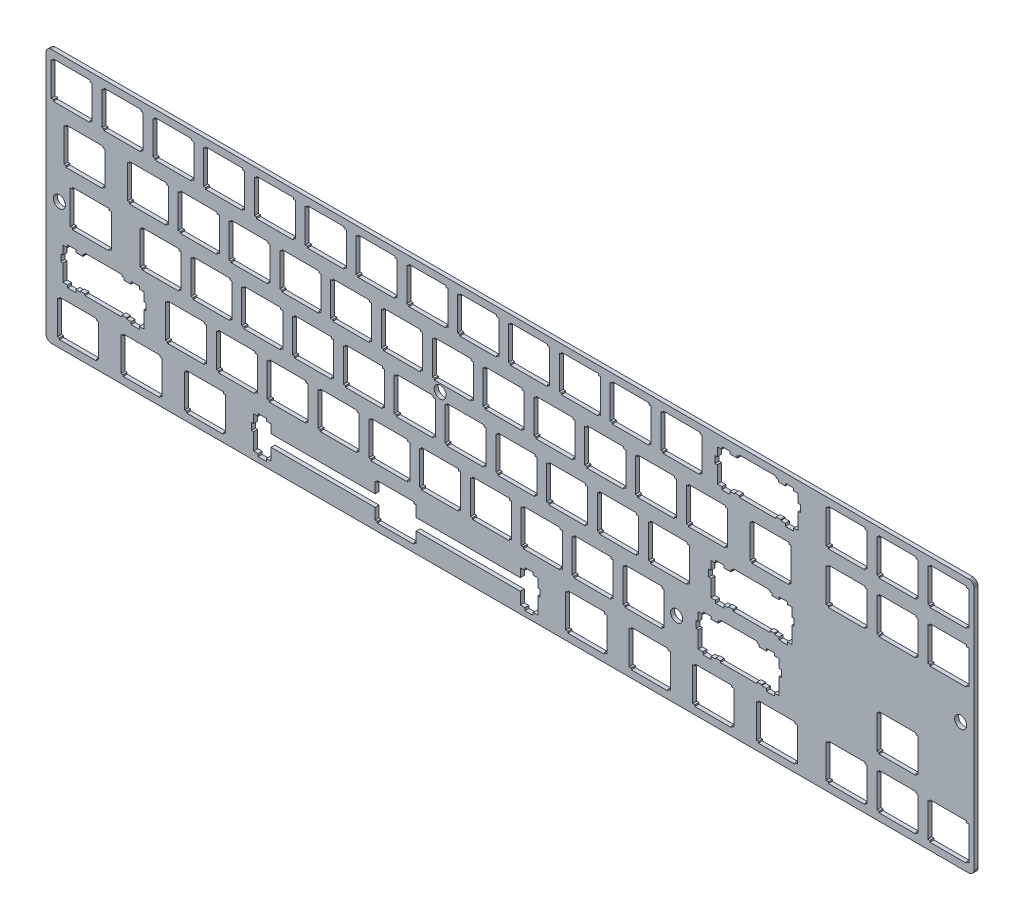
from build123d import *

# Parameters (mm, degrees)
MODEL_R             = 2.25
BOSS_EXTRUDE1_DEPTH = 1.5


with BuildPart() as part:
    # Model → Boss-Extrude1 (new body)
    with BuildSketch(Plane.XY):
        Polygon((346.115, 95.8536), (345.958, 95.8603), (2.096, 95.8603), (1.9389, 95.8536), (1.7818, 95.8356), (1.62884, 95.8053), (1.47588, 95.7626), (1.32981, 95.7076), (1.18787, 95.6426), (1.05006, 95.5657), (0.919152, 95.4786), (0.796505, 95.3809), (0.680752, 95.2747), (0.574643, 95.159), (0.4768, 95.0366), (0.389985, 94.9053), (0.312815, 94.7678), (0.248047, 94.6256), (0.192925, 94.4795), (0.150206, 94.3268), (0.119889, 94.1737), (0.101975, 94.0167), (0.0950846, 93.8597), (0.0950846, 49.660655), (0.0950846, 45.160655), (0.0950846, 2.40881), (0.101975, 2.25309), (0.119889, 2.09737), (0.150206, 1.94303), (0.192925, 1.79145), (0.248047, 1.644), (0.312815, 1.50206), (0.389985, 1.36563), (0.4768, 1.23472), (0.574643, 1.1107), (0.680752, 0.994943), (0.796505, 0.888834), (0.919152, 0.790995), (1.05006, 0.704176), (1.18787, 0.627006), (1.32981, 0.56224), (1.47588, 0.507118), (1.62884, 0.4644), (1.7818, 0.434082), (1.9389, 0.416168), (2.096, 0.410655), (345.958, 0.410655), (346.115, 0.416168), (346.272, 0.434082), (346.425, 0.4644), (346.577, 0.507118), (346.724, 0.56224), (346.866, 0.627006), (347.004, 0.704176), (347.135, 0.790995), (347.258, 0.888834), (347.373, 0.994943), (347.479, 1.1107), (347.577, 1.23472), (347.664, 1.36563), (347.741, 1.50206), (347.806, 1.644), (347.861, 1.79145), (347.904, 1.94303), (347.934, 2.09737), (347.952, 2.25309), (347.959, 2.41019), (347.959, 45.160655), (347.959, 49.660655), (347.959, 93.8597), (347.952, 94.0167), (347.934, 94.1737), (347.904, 94.3268), (347.861, 94.4795), (347.806, 94.6256), (347.741, 94.7678), (347.664, 94.9053), (347.577, 95.0366), (347.479, 95.159), (347.373, 95.2747), (347.258, 95.3809), (347.135, 95.4786), (347.004, 95.5657), (346.866, 95.6426), (346.724, 95.7076), (346.577, 95.7626), (346.425, 95.8053), (346.272, 95.8356), align=None)
        Polygon((5.2021, 16.3366), (5.2021, 16.9361), (19.0018, 16.9361), (19.0018, 16.3366), (19.801, 16.3366), (19.801, 3.73585), (19.0018, 3.73585), (19.0018, 3.13504), (5.2021, 3.13504), (5.2021, 3.73585), (4.40147, 3.73585), (4.40147, 16.3366), align=None, mode=Mode.SUBTRACT)
        Polygon((29.0132, 16.3366), (29.0132, 16.9361), (42.8128, 16.9361), (42.8128, 16.3366), (43.6136, 16.3366), (43.6136, 3.73585), (42.8128, 3.73585), (42.8128, 3.13504), (29.0132, 3.13504), (29.0132, 3.73585), (28.214, 3.73585), (28.214, 16.3366), align=None, mode=Mode.SUBTRACT)
        Polygon((52.8271, 16.3366), (52.8271, 16.9361), (66.6267, 16.9361), (66.6267, 16.3366), (67.4261, 16.3366), (67.4261, 3.73585), (66.6267, 3.73585), (66.6267, 3.13504), (52.8271, 3.13504), (52.8271, 3.73585), (52.0266, 3.73585), (52.0266, 16.3366), align=None, mode=Mode.SUBTRACT)
        Polygon((124.263, 16.3366), (124.263, 16.9361), (138.063, 16.9361), (138.063, 16.3366), (138.864, 16.3366), (138.864, 12.2356), (177.888, 12.2356), (177.888, 15.4657), (179.614, 15.4657), (179.614, 16.3849), (182.714, 16.3849), (182.714, 15.4657), (184.438, 15.4657), (184.438, 12.2356), (185.263, 12.2356), (185.263, 9.63524), (184.438, 9.63524), (184.438, 3.36655), (182.714, 3.36655), (182.714, 2.38538), (179.614, 2.38538), (179.614, 3.36655), (177.888, 3.36655), (177.888, 7.83551), (138.864, 7.83551), (138.864, 3.73585), (138.063, 3.73585), (138.063, 3.13504), (124.263, 3.13504), (124.263, 3.73585), (123.464, 3.73585), (123.464, 7.83551), (84.4381, 7.83551), (84.4381, 3.36655), (82.714, 3.36655), (82.714, 2.38538), (79.6135, 2.38538), (79.6135, 3.36655), (77.888, 3.36655), (77.888, 9.63524), (77.064, 9.63524), (77.064, 12.2356), (77.888, 12.2356), (77.888, 15.4657), (79.6135, 15.4657), (79.6135, 16.3849), (82.714, 16.3849), (82.714, 15.4657), (84.4381, 15.4657), (84.4381, 12.2356), (123.464, 12.2356), (123.464, 16.3366), align=None, mode=Mode.SUBTRACT)
        Polygon((29.326, 35.3868), (29.326, 34.5157), (30.2521, 34.5157), (31.976, 34.5157), (31.976, 35.4348), (35.0766, 35.4348), (35.0766, 34.5157), (36.8018, 34.5157), (36.8018, 31.2856), (37.6259, 31.2856), (37.6259, 28.6852), (36.8018, 28.6852), (36.8018, 22.4152), (35.0766, 22.4152), (35.0766, 21.4354), (31.976, 21.4354), (31.976, 22.4152), (30.2521, 22.4152), (30.2521, 22.7858), (29.326, 22.7858), (28.5268, 22.7858), (28.5268, 22.185), (14.7271, 22.185), (14.7271, 22.7858), (13.9265, 22.7858), (13.0018, 22.7858), (13.0018, 22.4152), (11.2765, 22.4152), (11.2765, 21.4354), (8.17591, 21.4354), (8.17591, 22.4152), (6.45199, 22.4152), (6.45199, 28.6852), (5.62652, 28.6852), (5.62652, 31.2856), (6.45199, 31.2856), (6.45199, 34.5157), (8.17591, 34.5157), (8.17591, 35.4348), (11.2765, 35.4348), (11.2765, 34.5157), (13.0018, 34.5157), (13.9265, 34.5157), (13.9265, 35.3868), (14.7271, 35.3868), (14.7271, 35.9876), (28.5268, 35.9876), (28.5268, 35.3868), align=None, mode=Mode.SUBTRACT)
        Polygon((45.6819, 35.3868), (45.6819, 35.9876), (59.4829, 35.9876), (59.4829, 35.3868), (60.2823, 35.3868), (60.2823, 22.7858), (59.4829, 22.7858), (59.4829, 22.185), (45.6819, 22.185), (45.6819, 22.7858), (44.8829, 22.7858), (44.8829, 35.3868), align=None, mode=Mode.SUBTRACT)
        Polygon((64.7319, 35.3868), (64.7319, 35.9876), (78.5329, 35.9876), (78.5329, 35.3868), (79.3323, 35.3868), (79.3323, 22.7858), (78.5329, 22.7858), (78.5329, 22.185), (64.7319, 22.185), (64.7319, 22.7858), (63.9329, 22.7858), (63.9329, 35.3868), align=None, mode=Mode.SUBTRACT)
        with BuildLine():
            ThreePointArc((5.0950846, 50.151223349), (7.3450846, 47.901223349), (5.0950846, 45.651223349))
            ThreePointArc((5.0950846, 45.651223349), (2.8450846, 47.901223349), (5.0950846, 50.151223349))
        make_face(mode=Mode.SUBTRACT)
        Polygon((83.7819, 35.3868), (83.7819, 35.9876), (97.5829, 35.9876), (97.5829, 35.3868), (98.3823, 35.3868), (98.3823, 22.7858), (97.5829, 22.7858), (97.5829, 22.185), (83.7819, 22.185), (83.7819, 22.7858), (82.9829, 22.7858), (82.9829, 35.3868), align=None, mode=Mode.SUBTRACT)
        Polygon((102.832, 35.3868), (102.832, 35.9876), (116.633, 35.9876), (116.633, 35.3868), (117.432, 35.3868), (117.432, 22.7858), (116.633, 22.7858), (116.633, 22.185), (102.832, 22.185), (102.832, 22.7858), (102.033, 22.7858), (102.033, 35.3868), align=None, mode=Mode.SUBTRACT)
        Polygon((121.882, 35.3868), (121.882, 35.9876), (135.683, 35.9876), (135.683, 35.3868), (136.482, 35.3868), (136.482, 22.7858), (135.683, 22.7858), (135.683, 22.185), (121.882, 22.185), (121.882, 22.7858), (121.083, 22.7858), (121.083, 35.3868), align=None, mode=Mode.SUBTRACT)
        Polygon((140.932, 35.3868), (140.932, 35.9876), (154.733, 35.9876), (154.733, 35.3868), (155.532, 35.3868), (155.532, 22.7858), (154.733, 22.7858), (154.733, 22.185), (140.932, 22.185), (140.932, 22.7858), (140.133, 22.7858), (140.133, 35.3868), align=None, mode=Mode.SUBTRACT)
        Polygon((159.982, 35.3868), (159.982, 35.9876), (173.783, 35.9876), (173.783, 35.3868), (174.582, 35.3868), (174.582, 22.7858), (173.783, 22.7858), (173.783, 22.185), (159.982, 22.185), (159.982, 22.7858), (159.183, 22.7858), (159.183, 35.3868), align=None, mode=Mode.SUBTRACT)
        Polygon((195.702, 16.3366), (195.702, 16.9361), (209.502, 16.9361), (209.502, 16.3366), (210.301, 16.3366), (210.301, 3.73585), (209.502, 3.73585), (209.502, 3.13504), (195.702, 3.13504), (195.702, 3.73585), (194.902, 3.73585), (194.902, 16.3366), align=None, mode=Mode.SUBTRACT)
        Polygon((219.513, 16.3366), (219.513, 16.9361), (233.313, 16.9361), (233.313, 16.3366), (234.114, 16.3366), (234.114, 3.73585), (233.313, 3.73585), (233.313, 3.13504), (219.513, 3.13504), (219.513, 3.73585), (218.714, 3.73585), (218.714, 16.3366), align=None, mode=Mode.SUBTRACT)
        Polygon((243.327, 16.3366), (243.327, 16.9361), (257.127, 16.9361), (257.127, 16.3366), (257.926, 16.3366), (257.926, 3.73585), (257.127, 3.73585), (257.127, 3.13504), (243.327, 3.13504), (243.327, 3.73585), (242.527, 3.73585), (242.527, 16.3366), align=None, mode=Mode.SUBTRACT)
        Polygon((267.138, 16.3366), (267.138, 16.9361), (280.938, 16.9361), (280.938, 16.3366), (281.739, 16.3366), (281.739, 3.73585), (280.938, 3.73585), (280.938, 3.13504), (267.138, 3.13504), (267.138, 3.73585), (266.339, 3.73585), (266.339, 16.3366), align=None, mode=Mode.SUBTRACT)
        Polygon((293.332, 16.3366), (293.332, 16.9361), (307.133, 16.9361), (307.133, 16.3366), (307.932, 16.3366), (307.932, 3.73585), (307.133, 3.73585), (307.133, 3.13504), (293.332, 3.13504), (293.332, 3.73585), (292.533, 3.73585), (292.533, 16.3366), align=None, mode=Mode.SUBTRACT)
        Polygon((312.382, 16.3366), (312.382, 16.9361), (326.183, 16.9361), (326.183, 16.3366), (326.982, 16.3366), (326.982, 3.73585), (326.183, 3.73585), (326.183, 3.13504), (312.382, 3.13504), (312.382, 3.73585), (311.583, 3.73585), (311.583, 16.3366), align=None, mode=Mode.SUBTRACT)
        Polygon((331.432, 16.3366), (331.432, 16.9361), (345.233, 16.9361), (345.233, 16.3366), (346.032, 16.3366), (346.032, 3.73585), (345.233, 3.73585), (345.233, 3.13504), (331.432, 3.13504), (331.432, 3.73585), (330.633, 3.73585), (330.633, 16.3366), align=None, mode=Mode.SUBTRACT)
        Polygon((179.032, 35.3868), (179.032, 35.9876), (192.833, 35.9876), (192.833, 35.3868), (193.632, 35.3868), (193.632, 22.7858), (192.833, 22.7858), (192.833, 22.185), (179.032, 22.185), (179.032, 22.7858), (178.233, 22.7858), (178.233, 35.3868), align=None, mode=Mode.SUBTRACT)
        Polygon((198.082, 35.3868), (198.082, 35.9876), (211.883, 35.9876), (211.883, 35.3868), (212.682, 35.3868), (212.682, 22.7858), (211.883, 22.7858), (211.883, 22.185), (198.082, 22.185), (198.082, 22.7858), (197.283, 22.7858), (197.283, 35.3868), align=None, mode=Mode.SUBTRACT)
        Polygon((217.132, 35.3868), (217.132, 35.9876), (230.933, 35.9876), (230.933, 35.3868), (231.732, 35.3868), (231.732, 22.7858), (230.933, 22.7858), (230.933, 22.185), (217.132, 22.185), (217.132, 22.7858), (216.333, 22.7858), (216.333, 35.3868), align=None, mode=Mode.SUBTRACT)
        with Locations((236.496, 29.175768349)):
            Circle(MODEL_R, mode=Mode.SUBTRACT)
        Polygon((252.851, 35.3868), (252.851, 35.9876), (266.652, 35.9876), (266.652, 35.3868), (267.451, 35.3868), (267.451, 34.5157), (268.377, 34.5157), (270.101, 34.5157), (270.101, 35.4348), (273.202, 35.4348), (273.202, 34.5157), (274.927, 34.5157), (274.927, 31.2856), (275.751, 31.2856), (275.751, 28.6852), (274.927, 28.6852), (274.927, 22.4152), (273.202, 22.4152), (273.202, 21.4354), (270.101, 21.4354), (270.101, 22.4152), (268.377, 22.4152), (268.377, 22.7858), (267.451, 22.7858), (266.652, 22.7858), (266.652, 22.185), (252.851, 22.185), (252.851, 22.7858), (252.052, 22.7858), (251.127, 22.7858), (251.127, 22.4152), (249.402, 22.4152), (249.402, 21.4354), (246.301, 21.4354), (246.301, 22.4152), (244.577, 22.4152), (244.577, 28.6852), (243.751, 28.6852), (243.751, 31.2856), (244.577, 31.2856), (244.577, 34.5157), (246.301, 34.5157), (246.301, 35.4348), (249.402, 35.4348), (249.402, 34.5157), (251.127, 34.5157), (252.052, 34.5157), (252.052, 35.3868), align=None, mode=Mode.SUBTRACT)
        Polygon((312.382, 35.3868), (312.382, 35.9876), (326.183, 35.9876), (326.183, 35.3868), (326.982, 35.3868), (326.982, 22.7858), (326.183, 22.7858), (326.183, 22.185), (312.382, 22.185), (312.382, 22.7858), (311.583, 22.7858), (311.583, 35.3868), align=None, mode=Mode.SUBTRACT)
        Polygon((272.214, 54.4354), (272.214, 53.5658), (273.138, 53.5658), (274.864, 53.5658), (274.864, 54.4862), (277.964, 54.4862), (277.964, 53.5658), (279.688, 53.5658), (279.688, 50.3357), (280.513, 50.3357), (280.513, 47.7365), (279.688, 47.7365), (279.688, 41.4666), (277.964, 41.4666), (277.964, 40.4855), (274.864, 40.4855), (274.864, 41.4666), (273.138, 41.4666), (273.138, 41.8359), (272.214, 41.8359), (271.413, 41.8359), (271.413, 41.2365), (257.613, 41.2365), (257.613, 41.8359), (256.814, 41.8359), (255.888, 41.8359), (255.888, 41.4666), (254.163, 41.4666), (254.163, 40.4855), (251.063, 40.4855), (251.063, 41.4666), (249.338, 41.4666), (249.338, 47.7365), (248.514, 47.7365), (248.514, 50.3357), (249.338, 50.3357), (249.338, 53.5658), (251.063, 53.5658), (251.063, 54.4862), (254.163, 54.4862), (254.163, 53.5658), (255.888, 53.5658), (256.814, 53.5658), (256.814, 54.4354), (257.613, 54.4354), (257.613, 55.0362), (271.413, 55.0362), (271.413, 54.4354), align=None, mode=Mode.SUBTRACT)
        with BuildLine():
            ThreePointArc((342.959, 45.651223349), (340.709, 47.901223349), (342.959, 50.151223349))
            ThreePointArc((342.959, 50.151223349), (345.209, 47.901223349), (342.959, 45.651223349))
        make_face(mode=Mode.SUBTRACT)
        Polygon((9.96322, 54.4354), (9.96322, 55.0362), (23.7629, 55.0362), (23.7629, 54.4354), (24.5635, 54.4354), (24.5635, 41.8359), (23.7629, 41.8359), (23.7629, 41.2365), (9.96322, 41.2365), (9.96322, 41.8359), (9.16397, 41.8359), (9.16397, 54.4354), align=None, mode=Mode.SUBTRACT)
        Polygon((36.1569, 54.4354), (36.1569, 55.0362), (49.9579, 55.0362), (49.9579, 54.4354), (50.7573, 54.4354), (50.7573, 41.8359), (49.9579, 41.8359), (49.9579, 41.2365), (36.1569, 41.2365), (36.1569, 41.8359), (35.3579, 41.8359), (35.3579, 54.4354), align=None, mode=Mode.SUBTRACT)
        Polygon((55.2069, 54.4354), (55.2069, 55.0362), (69.0079, 55.0362), (69.0079, 54.4354), (69.8073, 54.4354), (69.8073, 41.8359), (69.0079, 41.8359), (69.0079, 41.2365), (55.2069, 41.2365), (55.2069, 41.8359), (54.4079, 41.8359), (54.4079, 54.4354), align=None, mode=Mode.SUBTRACT)
        Polygon((74.2569, 54.4354), (74.2569, 55.0362), (88.0579, 55.0362), (88.0579, 54.4354), (88.8573, 54.4354), (88.8573, 41.8359), (88.0579, 41.8359), (88.0579, 41.2365), (74.2569, 41.2365), (74.2569, 41.8359), (73.4579, 41.8359), (73.4579, 54.4354), align=None, mode=Mode.SUBTRACT)
        Polygon((7.58197, 73.4868), (7.58197, 74.0847), (21.383, 74.0847), (21.383, 73.4868), (22.1823, 73.4868), (22.1823, 60.8859), (21.383, 60.8859), (21.383, 60.2865), (7.58197, 60.2865), (7.58197, 60.8859), (6.78272, 60.8859), (6.78272, 73.4868), align=None, mode=Mode.SUBTRACT)
        Polygon((31.3958, 73.4868), (31.3958, 74.0847), (45.1954, 74.0847), (45.1954, 73.4868), (45.9962, 73.4868), (45.9962, 60.8859), (45.1954, 60.8859), (45.1954, 60.2865), (31.3958, 60.2865), (31.3958, 60.8859), (30.5952, 60.8859), (30.5952, 73.4868), align=None, mode=Mode.SUBTRACT)
        Polygon((50.4458, 73.4868), (50.4458, 74.0847), (64.2454, 74.0847), (64.2454, 73.4868), (65.0462, 73.4868), (65.0462, 60.8859), (64.2454, 60.8859), (64.2454, 60.2865), (50.4458, 60.2865), (50.4458, 60.8859), (49.6454, 60.8859), (49.6454, 73.4868), align=None, mode=Mode.SUBTRACT)
        Polygon((69.4944, 73.4868), (69.4944, 74.0847), (83.2954, 74.0847), (83.2954, 73.4868), (84.0962, 73.4868), (84.0962, 60.8859), (83.2954, 60.8859), (83.2954, 60.2865), (69.4944, 60.2865), (69.4944, 60.8859), (68.6954, 60.8859), (68.6954, 73.4868), align=None, mode=Mode.SUBTRACT)
        Polygon((93.3069, 54.4354), (93.3069, 55.0362), (107.108, 55.0362), (107.108, 54.4354), (107.907, 54.4354), (107.907, 41.8359), (107.108, 41.8359), (107.108, 41.2365), (93.3069, 41.2365), (93.3069, 41.8359), (92.5079, 41.8359), (92.5079, 54.4354), align=None, mode=Mode.SUBTRACT)
        Polygon((112.357, 54.4354), (112.357, 55.0362), (126.158, 55.0362), (126.158, 54.4354), (126.957, 54.4354), (126.957, 41.8359), (126.158, 41.8359), (126.158, 41.2365), (112.357, 41.2365), (112.357, 41.8359), (111.558, 41.8359), (111.558, 54.4354), align=None, mode=Mode.SUBTRACT)
        Polygon((131.407, 54.4354), (131.407, 55.0362), (145.208, 55.0362), (145.208, 54.4354), (146.007, 54.4354), (146.007, 41.8359), (145.208, 41.8359), (145.208, 41.2365), (131.407, 41.2365), (131.407, 41.8359), (130.608, 41.8359), (130.608, 54.4354), align=None, mode=Mode.SUBTRACT)
        Polygon((150.457, 54.4354), (150.457, 55.0362), (164.258, 55.0362), (164.258, 54.4354), (165.057, 54.4354), (165.057, 41.8359), (164.258, 41.8359), (164.258, 41.2365), (150.457, 41.2365), (150.457, 41.8359), (149.658, 41.8359), (149.658, 54.4354), align=None, mode=Mode.SUBTRACT)
        with Locations((147.859905544, 57.463929355)):
            Circle(MODEL_R, mode=Mode.SUBTRACT)
        Polygon((88.5444, 73.4868), (88.5444, 74.0847), (102.345, 74.0847), (102.345, 73.4868), (103.146, 73.4868), (103.146, 60.8859), (102.345, 60.8859), (102.345, 60.2865), (88.5444, 60.2865), (88.5444, 60.8859), (87.744, 60.8859), (87.744, 73.4868), align=None, mode=Mode.SUBTRACT)
        Polygon((107.594, 73.4868), (107.594, 74.0847), (121.395, 74.0847), (121.395, 73.4868), (122.196, 73.4868), (122.196, 60.8859), (121.395, 60.8859), (121.395, 60.2865), (107.594, 60.2865), (107.594, 60.8859), (106.794, 60.8859), (106.794, 73.4868), align=None, mode=Mode.SUBTRACT)
        Polygon((126.644, 73.4868), (126.644, 74.0847), (140.445, 74.0847), (140.445, 73.4868), (141.245, 73.4868), (141.245, 60.8859), (140.445, 60.8859), (140.445, 60.2865), (126.644, 60.2865), (126.644, 60.8859), (125.845, 60.8859), (125.845, 73.4868), align=None, mode=Mode.SUBTRACT)
        Polygon((145.696, 73.4868), (145.696, 74.0847), (159.495, 74.0847), (159.495, 73.4868), (160.296, 73.4868), (160.296, 60.8859), (159.495, 60.8859), (159.495, 60.2865), (145.696, 60.2865), (145.696, 60.8859), (144.895, 60.8859), (144.895, 73.4868), align=None, mode=Mode.SUBTRACT)
        Polygon((164.746, 73.4868), (164.746, 74.0847), (178.545, 74.0847), (178.545, 73.4868), (179.346, 73.4868), (179.346, 60.8859), (178.545, 60.8859), (178.545, 60.2865), (164.746, 60.2865), (164.746, 60.8859), (163.945, 60.8859), (163.945, 73.4868), align=None, mode=Mode.SUBTRACT)
        Polygon((2.82084, 92.5354), (2.82084, 93.1347), (16.6205, 93.1347), (16.6205, 92.5354), (17.4212, 92.5354), (17.4212, 79.9345), (16.6205, 79.9345), (16.6205, 79.3351), (2.82084, 79.3351), (2.82084, 79.9345), (2.0202, 79.9345), (2.0202, 92.5354), align=None, mode=Mode.SUBTRACT)
        Polygon((21.8708, 92.5354), (21.8708, 93.1347), (35.669, 93.1347), (35.669, 92.5354), (36.4712, 92.5354), (36.4712, 79.9345), (35.669, 79.9345), (35.669, 79.3351), (21.8708, 79.3351), (21.8708, 79.9345), (21.0688, 79.9345), (21.0688, 92.5354), align=None, mode=Mode.SUBTRACT)
        Polygon((40.9194, 92.5354), (40.9194, 93.1347), (54.719, 93.1347), (54.719, 92.5354), (55.5212, 92.5354), (55.5212, 79.9345), (54.719, 79.9345), (54.719, 79.3351), (40.9194, 79.3351), (40.9194, 79.9345), (40.1189, 79.9345), (40.1189, 92.5354), align=None, mode=Mode.SUBTRACT)
        Polygon((59.968, 92.5354), (59.968, 93.1347), (73.7704, 93.1347), (73.7704, 92.5354), (74.5712, 92.5354), (74.5712, 79.9345), (73.7704, 79.9345), (73.7704, 79.3351), (59.968, 79.3351), (59.968, 79.9345), (59.1689, 79.9345), (59.1689, 92.5354), align=None, mode=Mode.SUBTRACT)
        Polygon((79.0194, 92.5354), (79.0194, 93.1347), (92.8204, 93.1347), (92.8204, 92.5354), (93.6198, 92.5354), (93.6198, 79.9345), (92.8204, 79.9345), (92.8204, 79.3351), (79.0194, 79.3351), (79.0194, 79.9345), (78.219, 79.9345), (78.219, 92.5354), align=None, mode=Mode.SUBTRACT)
        Polygon((98.0694, 92.5354), (98.0694, 93.1347), (111.869, 93.1347), (111.869, 92.5354), (112.67, 92.5354), (112.67, 79.9345), (111.869, 79.9345), (111.869, 79.3351), (98.0694, 79.3351), (98.0694, 79.9345), (97.2689, 79.9345), (97.2689, 92.5354), align=None, mode=Mode.SUBTRACT)
        Polygon((117.119, 92.5354), (117.119, 93.1347), (130.92, 93.1347), (130.92, 92.5354), (131.72, 92.5354), (131.72, 79.9345), (130.92, 79.9345), (130.92, 79.3351), (117.119, 79.3351), (117.119, 79.9345), (116.319, 79.9345), (116.319, 92.5354), align=None, mode=Mode.SUBTRACT)
        Polygon((136.171, 92.5354), (136.171, 93.1347), (149.97, 93.1347), (149.97, 92.5354), (150.77, 92.5354), (150.77, 79.9345), (149.97, 79.9345), (149.97, 79.3351), (136.171, 79.3351), (136.171, 79.9345), (135.37, 79.9345), (135.37, 92.5354), align=None, mode=Mode.SUBTRACT)
        Polygon((155.221, 92.5354), (155.221, 93.1347), (169.02, 93.1347), (169.02, 92.5354), (169.821, 92.5354), (169.821, 79.9345), (169.02, 79.9345), (169.02, 79.3351), (155.221, 79.3351), (155.221, 79.9345), (154.42, 79.9345), (154.42, 92.5354), align=None, mode=Mode.SUBTRACT)
        Polygon((169.507, 54.4354), (169.507, 55.0362), (183.308, 55.0362), (183.308, 54.4354), (184.107, 54.4354), (184.107, 41.8359), (183.308, 41.8359), (183.308, 41.2365), (169.507, 41.2365), (169.507, 41.8359), (168.708, 41.8359), (168.708, 54.4354), align=None, mode=Mode.SUBTRACT)
        Polygon((188.557, 54.4354), (188.557, 55.0362), (202.358, 55.0362), (202.358, 54.4354), (203.157, 54.4354), (203.157, 41.8359), (202.358, 41.8359), (202.358, 41.2365), (188.557, 41.2365), (188.557, 41.8359), (187.758, 41.8359), (187.758, 54.4354), align=None, mode=Mode.SUBTRACT)
        Polygon((207.607, 54.4354), (207.607, 55.0362), (221.408, 55.0362), (221.408, 54.4354), (222.207, 54.4354), (222.207, 41.8359), (221.408, 41.8359), (221.408, 41.2365), (207.607, 41.2365), (207.607, 41.8359), (206.808, 41.8359), (206.808, 54.4354), align=None, mode=Mode.SUBTRACT)
        Polygon((226.657, 54.4354), (226.657, 55.0362), (240.458, 55.0362), (240.458, 54.4354), (241.257, 54.4354), (241.257, 41.8359), (240.458, 41.8359), (240.458, 41.2365), (226.657, 41.2365), (226.657, 41.8359), (225.858, 41.8359), (225.858, 54.4354), align=None, mode=Mode.SUBTRACT)
        Polygon((183.796, 73.4868), (183.796, 74.0847), (197.595, 74.0847), (197.595, 73.4868), (198.396, 73.4868), (198.396, 60.8859), (197.595, 60.8859), (197.595, 60.2865), (183.796, 60.2865), (183.796, 60.8859), (182.995, 60.8859), (182.995, 73.4868), align=None, mode=Mode.SUBTRACT)
        Polygon((202.846, 73.4868), (202.846, 74.0847), (216.645, 74.0847), (216.645, 73.4868), (217.446, 73.4868), (217.446, 60.8859), (216.645, 60.8859), (216.645, 60.2865), (202.846, 60.2865), (202.846, 60.8859), (202.045, 60.8859), (202.045, 73.4868), align=None, mode=Mode.SUBTRACT)
        Polygon((221.896, 73.4868), (221.896, 74.0847), (235.695, 74.0847), (235.695, 73.4868), (236.496, 73.4868), (236.496, 60.8859), (235.695, 60.8859), (235.695, 60.2865), (221.896, 60.2865), (221.896, 60.8859), (221.095, 60.8859), (221.095, 73.4868), align=None, mode=Mode.SUBTRACT)
        Polygon((240.946, 73.4868), (240.946, 74.0847), (254.744, 74.0847), (254.744, 73.4868), (255.546, 73.4868), (255.546, 60.8859), (254.744, 60.8859), (254.744, 60.2865), (240.946, 60.2865), (240.946, 60.8859), (240.145, 60.8859), (240.145, 73.4868), align=None, mode=Mode.SUBTRACT)
        Polygon((264.757, 73.4868), (264.757, 74.0847), (278.558, 74.0847), (278.558, 73.4868), (279.357, 73.4868), (279.357, 60.8859), (278.558, 60.8859), (278.558, 60.2865), (264.757, 60.2865), (264.757, 60.8859), (263.958, 60.8859), (263.958, 73.4868), align=None, mode=Mode.SUBTRACT)
        Polygon((293.332, 73.4868), (293.332, 74.0847), (307.133, 74.0847), (307.133, 73.4868), (307.932, 73.4868), (307.932, 60.8859), (307.133, 60.8859), (307.133, 60.2865), (293.332, 60.2865), (293.332, 60.8859), (292.533, 60.8859), (292.533, 73.4868), align=None, mode=Mode.SUBTRACT)
        Polygon((312.382, 73.4868), (312.382, 74.0847), (326.183, 74.0847), (326.183, 73.4868), (326.982, 73.4868), (326.982, 60.8859), (326.183, 60.8859), (326.183, 60.2865), (312.382, 60.2865), (312.382, 60.8859), (311.583, 60.8859), (311.583, 73.4868), align=None, mode=Mode.SUBTRACT)
        Polygon((331.432, 73.4868), (331.432, 74.0847), (345.233, 74.0847), (345.233, 73.4868), (346.032, 73.4868), (346.032, 60.8859), (345.233, 60.8859), (345.233, 60.2865), (331.432, 60.2865), (331.432, 60.8859), (330.633, 60.8859), (330.633, 73.4868), align=None, mode=Mode.SUBTRACT)
        Polygon((174.271, 92.5354), (174.271, 93.1347), (188.07, 93.1347), (188.07, 92.5354), (188.871, 92.5354), (188.871, 79.9345), (188.07, 79.9345), (188.07, 79.3351), (174.271, 79.3351), (174.271, 79.9345), (173.47, 79.9345), (173.47, 92.5354), align=None, mode=Mode.SUBTRACT)
        Polygon((193.321, 92.5354), (193.321, 93.1347), (207.12, 93.1347), (207.12, 92.5354), (207.921, 92.5354), (207.921, 79.9345), (207.12, 79.9345), (207.12, 79.3351), (193.321, 79.3351), (193.321, 79.9345), (192.52, 79.9345), (192.52, 92.5354), align=None, mode=Mode.SUBTRACT)
        Polygon((212.371, 92.5354), (212.371, 93.1347), (226.17, 93.1347), (226.17, 92.5354), (226.971, 92.5354), (226.971, 79.9345), (226.17, 79.9345), (226.17, 79.3351), (212.371, 79.3351), (212.371, 79.9345), (211.57, 79.9345), (211.57, 92.5354), align=None, mode=Mode.SUBTRACT)
        Polygon((231.421, 92.5354), (231.421, 93.1347), (245.22, 93.1347), (245.22, 92.5354), (246.021, 92.5354), (246.021, 79.9345), (245.22, 79.9345), (245.22, 79.3351), (231.421, 79.3351), (231.421, 79.9345), (230.62, 79.9345), (230.62, 92.5354), align=None, mode=Mode.SUBTRACT)
        Polygon((259.996, 92.5354), (259.996, 93.1347), (273.795, 93.1347), (273.795, 92.5354), (274.596, 92.5354), (274.596, 91.6658), (275.521, 91.6658), (277.246, 91.6658), (277.246, 92.5862), (280.345, 92.5862), (280.345, 91.6658), (282.071, 91.6658), (282.071, 88.4357), (282.896, 88.4357), (282.896, 85.8354), (282.071, 85.8354), (282.071, 79.5651), (280.345, 79.5651), (280.345, 78.5855), (277.246, 78.5855), (277.246, 79.5651), (275.521, 79.5651), (275.521, 79.9345), (274.596, 79.9345), (273.795, 79.9345), (273.795, 79.3351), (259.996, 79.3351), (259.996, 79.9345), (259.195, 79.9345), (258.27, 79.9345), (258.27, 79.5651), (256.545, 79.5651), (256.545, 78.5855), (253.446, 78.5855), (253.446, 79.5651), (251.721, 79.5651), (251.721, 85.8354), (250.895, 85.8354), (250.895, 88.4357), (251.721, 88.4357), (251.721, 91.6658), (253.446, 91.6658), (253.446, 92.5862), (256.545, 92.5862), (256.545, 91.6658), (258.27, 91.6658), (259.195, 91.6658), (259.195, 92.5354), align=None, mode=Mode.SUBTRACT)
        Polygon((293.332, 92.5354), (293.332, 93.1347), (307.133, 93.1347), (307.133, 92.5354), (307.932, 92.5354), (307.932, 79.9345), (307.133, 79.9345), (307.133, 79.3351), (293.332, 79.3351), (293.332, 79.9345), (292.533, 79.9345), (292.533, 92.5354), align=None, mode=Mode.SUBTRACT)
        Polygon((312.382, 92.5354), (312.382, 93.1347), (326.183, 93.1347), (326.183, 92.5354), (326.982, 92.5354), (326.982, 79.9345), (326.183, 79.9345), (326.183, 79.3351), (312.382, 79.3351), (312.382, 79.9345), (311.583, 79.9345), (311.583, 92.5354), align=None, mode=Mode.SUBTRACT)
        Polygon((331.432, 92.5354), (331.432, 93.1347), (345.233, 93.1347), (345.233, 92.5354), (346.032, 92.5354), (346.032, 79.9345), (345.233, 79.9345), (345.233, 79.3351), (331.432, 79.3351), (331.432, 79.9345), (330.633, 79.9345), (330.633, 92.5354), align=None, mode=Mode.SUBTRACT)
    extrude(amount=BOSS_EXTRUDE1_DEPTH)


solid = part.part
